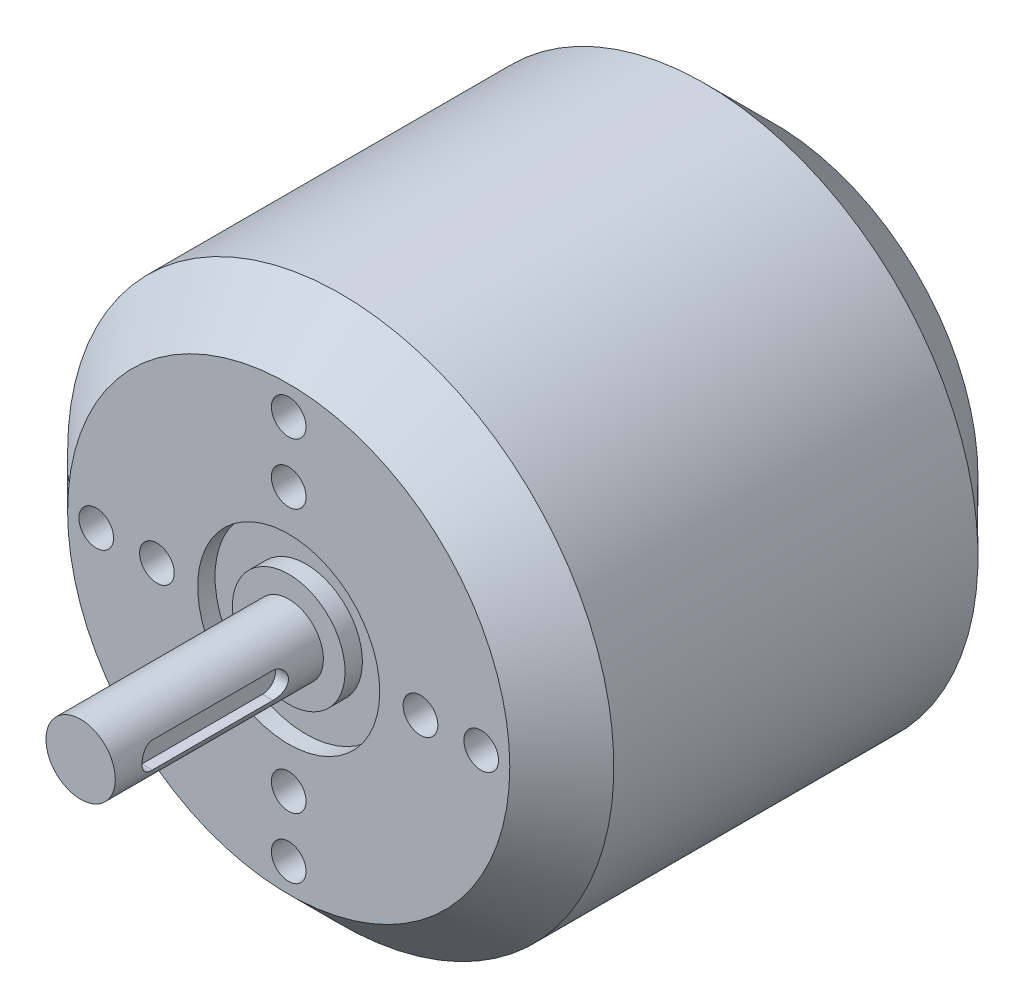
from build123d import *

# Parameters (mm, degrees)
SKETCH1_R           = 31.5
BOSS_EXTRUDE1_DEPTH = 42
SKETCH2_R           = 31.5
BOSS_EXTRUDE2_DEPTH = 6
CHAMFER1_SIZE       = 6
SKETCH4_R           = 31.5
BOSS_EXTRUDE3_DEPTH = 8
CHAMFER2_SIZE       = 8
SKETCH6_R           = 7.5
BOSS_EXTRUDE4_DEPTH = 1
SKETCH7_R           = 4
BOSS_EXTRUDE5_DEPTH = 24
SKETCH10_R          = 2
CUT_EXTRUDE4_DEPTH  = 8
CUT_EXTRUDE5_DEPTH  = 10
SKETCH12_R          = 10.5
SKETCH12_R_2        = 6.5
CUT_EXTRUDE6_DEPTH  = 2


with BuildPart() as part:
    # Sketch1 → Boss-Extrude1 (new body)
    with BuildSketch(Plane.XY):
        with Locations(Location((0, 0, 0), (0, 0, 180))):
            Circle(SKETCH1_R)
    extrude(amount=BOSS_EXTRUDE1_DEPTH)

    # Sketch2 → Boss-Extrude2 (add)
    with BuildSketch(Plane.XY.offset(42)):
        with Locations(Location((0, 0, 0), (0, 0, 180))):
            Circle(SKETCH2_R)
    extrude(amount=BOSS_EXTRUDE2_DEPTH)

    # Chamfer1
    chamfer1_edges = [part.edges().sort_by_distance(p)[0] for p in [
        (31.5, 0, 48),
    ]]
    chamfer(chamfer1_edges, length=CHAMFER1_SIZE)

    # Sketch4 → Boss-Extrude3 (add)
    with BuildSketch(Plane(origin=(0, 0, 0), x_dir=(-1, 0, 0), z_dir=(0, 0, -1))):
        Circle(SKETCH4_R)
    extrude(amount=BOSS_EXTRUDE3_DEPTH)

    # Chamfer2
    chamfer2_edges = [part.edges().sort_by_distance(p)[0] for p in [
        (31.5, 0, -8),
    ]]
    chamfer(chamfer2_edges, length=CHAMFER2_SIZE)

    # Sketch6 → Boss-Extrude4 (add)
    with BuildSketch(Plane(origin=(0, 0, -8), x_dir=(-1, 0, 0), z_dir=(0, 0, -1))):
        Circle(SKETCH6_R)
    extrude(amount=BOSS_EXTRUDE4_DEPTH)

    # Sketch7 → Boss-Extrude5 (add)
    with BuildSketch(Plane.XY.offset(48)):
        Circle(SKETCH7_R)
    extrude(amount=BOSS_EXTRUDE5_DEPTH)

    # Sketch10 → Cut-Extrude4 (cut)
    with BuildSketch(Plane.XY.offset(48)):
        with Locations((0, 15.2)):
            Circle(SKETCH10_R)
        with Locations((0, 22.2)):
            Circle(SKETCH10_R)
        with Locations((22.2, 0)):
            Circle(SKETCH10_R)
        with Locations((15.2, 0)):
            Circle(SKETCH10_R)
        with Locations((0, -22.2)):
            Circle(SKETCH10_R)
        with Locations((0, -15.2)):
            Circle(SKETCH10_R)
        with Locations((-22.2, 0)):
            Circle(SKETCH10_R)
        with Locations((-15.2, 0)):
            Circle(SKETCH10_R)
    extrude(amount=-CUT_EXTRUDE4_DEPTH, mode=Mode.SUBTRACT)

    # Sketch11 → Cut-Extrude5 (cut)
    with BuildSketch(Plane(origin=(2.5, 0, 0), x_dir=(0, 0, -1), z_dir=(1, 0, 0))):
        with BuildLine():
            Line((-67.418537693, 1.5), (-53.527084748, 1.5))
            ThreePointArc((-53.527084748, 1.5), (-52.027084748, 0), (-53.527084748, -1.5))
            Line((-53.527084748, -1.5), (-67.418537693, -1.5))
            ThreePointArc((-67.418537693, -1.5), (-68.918537693, 0), (-67.418537693, 1.5))
        make_face()
    extrude(amount=CUT_EXTRUDE5_DEPTH, mode=Mode.SUBTRACT)

    # Sketch12 → Cut-Extrude6 (cut)
    with BuildSketch(Plane.XY.offset(48)):
        Circle(SKETCH12_R)
        Circle(SKETCH12_R_2, mode=Mode.SUBTRACT)
    extrude(amount=-CUT_EXTRUDE6_DEPTH, mode=Mode.SUBTRACT)


solid = part.part
